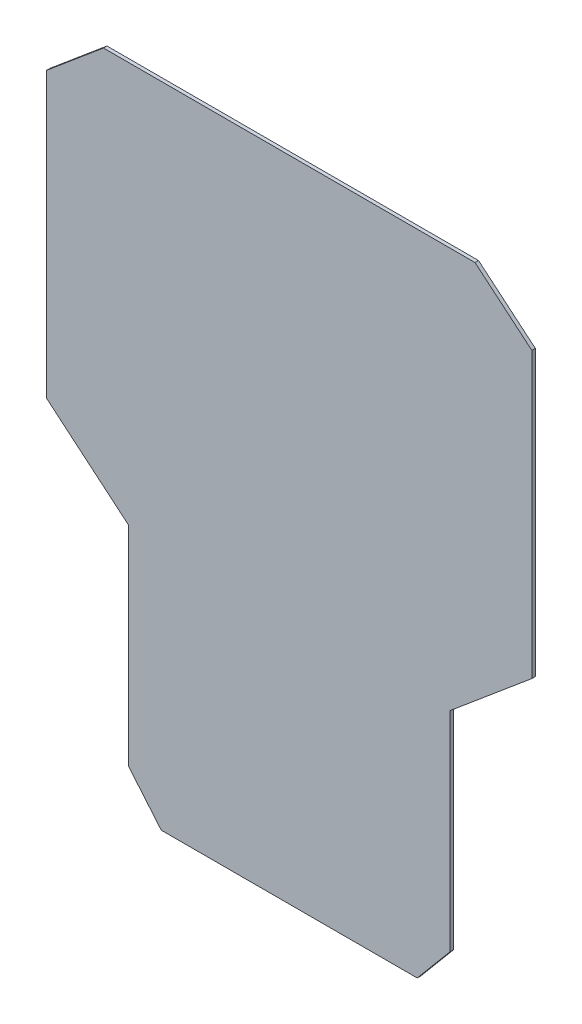
from build123d import *

# Parameters (mm, degrees)
RESSALTO_EXTRUS_O1_DEPTH = 1.5


with BuildPart() as part:
    # Esboço1 → Ressalto-extrusão1 (new body)
    with BuildSketch(Plane.XY):
        Polygon((-69, -140.409741205), (-54.87061576, -157.248485634), (54.87061576, -157.248485634), (69, -140.409741205), (69, -50.89303323), (104, -21.524546139), (104, 100.307715929), (79.636029766, 120.751514366), (-79.636029766, 120.751514366), (-104, 100.307715929), (-104, -21.524546139), (-69, -50.89303323), align=None)
    extrude(amount=RESSALTO_EXTRUS_O1_DEPTH)


solid = part.part
